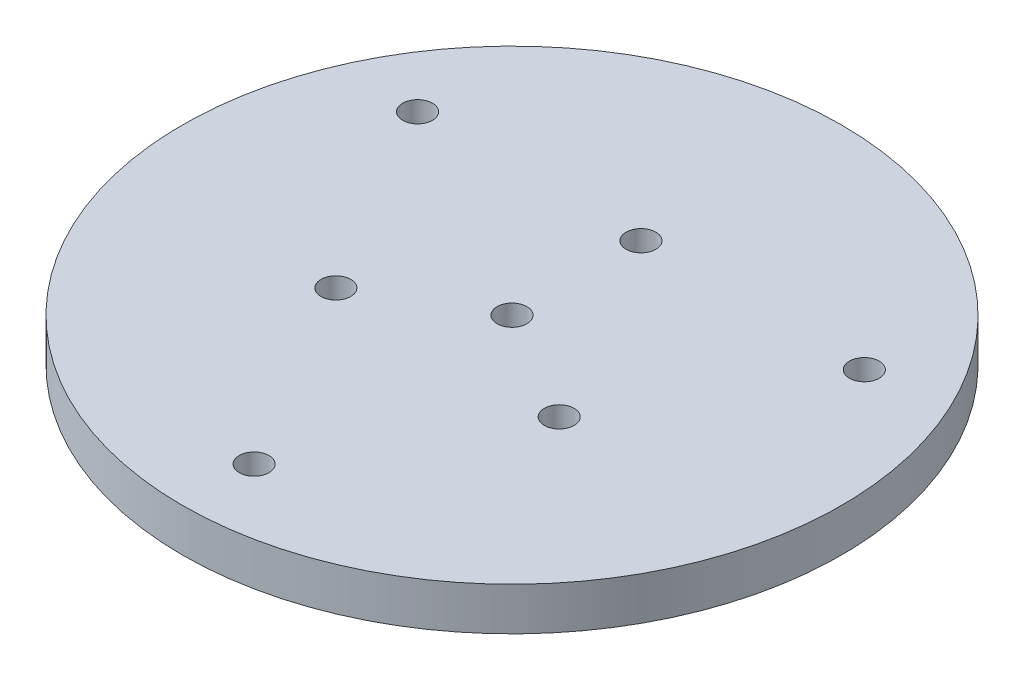
from build123d import *

# Parameters (mm, degrees)
SKETCH1_R           = 73.025
SKETCH1_R_2         = 3.3
BOSS_EXTRUDE1_DEPTH = 4.7625


with BuildPart() as part:
    # Sketch1 → Boss-Extrude1 (new body, symmetric)
    with BuildSketch(Plane(origin=(0, 0, 0), x_dir=(1, 0, 0), z_dir=(0, 1, 0))):
        Circle(SKETCH1_R)
        Circle(SKETCH1_R_2, mode=Mode.SUBTRACT)
        with Locations((0, -57.15)):
            Circle(SKETCH1_R_2, mode=Mode.SUBTRACT)
        with Locations((-49.493351826, 28.575)):
            Circle(SKETCH1_R_2, mode=Mode.SUBTRACT)
        with Locations((49.493351826, 28.575)):
            Circle(SKETCH1_R_2, mode=Mode.SUBTRACT)
        with Locations((24.746675913, -14.2875)):
            Circle(SKETCH1_R_2, mode=Mode.SUBTRACT)
        with Locations((-24.746675913, -14.2875)):
            Circle(SKETCH1_R_2, mode=Mode.SUBTRACT)
        with Locations((0, 28.575)):
            Circle(SKETCH1_R_2, mode=Mode.SUBTRACT)
    extrude(amount=BOSS_EXTRUDE1_DEPTH, both=True)


solid = part.part
